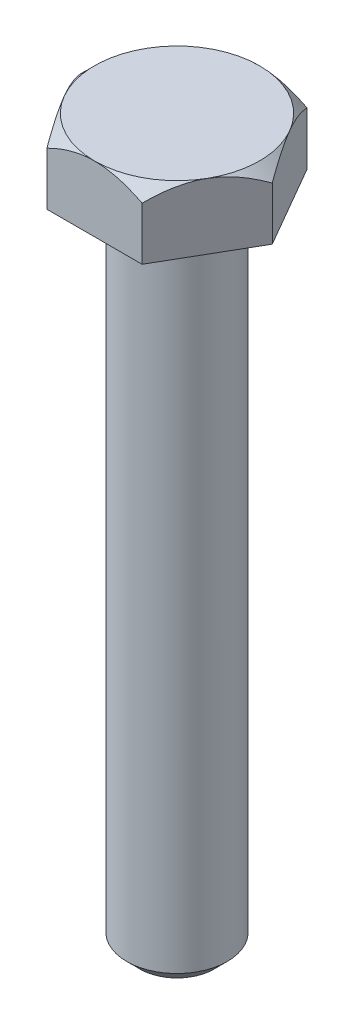
from build123d import *

# Parameters (mm, degrees)
EXTRUDE_1_DEPTH     = 5
SKETCH_8_OUTSIDE_W  = 22.464
SKETCH_8_OUTSIDE_H  = 20.522
SKETCH_8_OUTSIDE_R  = 6.278684177
CUT_EXTRUDE_1_DEPTH = 1
CUT_EXTRUDE_1_DRAFT = -45
SKETCH_9_R          = 3.825
BOLT_LENGTH_DEPTH   = 50
FILLET_1_R          = 1
CHAMFER_1_SIZE      = 1


with BuildPart() as part:
    # Эскиз6 → Бобышка-Вытянуть1 (new body)
    with BuildSketch(Plane(origin=(0, 0, 0), x_dir=(1, 0, 0), z_dir=(0, 1, 0))):
        Polygon((7.25, 0), (3.625, 6.278684177), (-3.625, 6.278684177), (-7.25, 0), (-3.625, -6.278684177), (3.625, -6.278684177), align=None)
    extrude(amount=EXTRUDE_1_DEPTH)


with BuildPart() as cut_extrude_1_tool:
    # Эскиз8 outside → Вырез-Вытянуть1 (with draft: the straight prism first)
    with BuildSketch(Plane(origin=(0, 5, 0), x_dir=(1, 0, 0), z_dir=(0, 1, 0))):
        Rectangle(SKETCH_8_OUTSIDE_W, SKETCH_8_OUTSIDE_H)
        Circle(SKETCH_8_OUTSIDE_R, mode=Mode.SUBTRACT)
    extrude(amount=-CUT_EXTRUDE_1_DEPTH)
    # Вырез-Вытянуть1: the draft: its side faces are tilted about the plane it starts from
    cut_extrude_1_sides = [cut_extrude_1_tool.faces().sort_by_distance(p)[0] for p in [
        (0, 4.5, 10.261),
        (11.232, 4.5, 0),
        (0, 4.5, -10.261),
        (-11.232, 4.5, 0),
        (-6.278684177, 4.5, 0),
    ]]
    draft(cut_extrude_1_sides, Plane(origin=(0, 5, 0), x_dir=(1, 0, 0), z_dir=(0, 1, 0)), CUT_EXTRUDE_1_DRAFT)


with BuildPart() as part_1:
    add(part.part)

    # Вырез-Вытянуть1: cut by cut_extrude_1_tool
    add(cut_extrude_1_tool.part, mode=Mode.SUBTRACT)

    # Эскиз9 → bolt length (add)
    with BuildSketch(Plane.XZ):
        with Locations(Location((0, 0, 0), (0, 0, 90))):  # turned: the seam where the file's is
            Circle(SKETCH_9_R)
    extrude(amount=BOLT_LENGTH_DEPTH)

    # Скругление1
    fillet_1_edges = [part_1.edges().sort_by_distance(p)[0] for p in [
        (0, 0, -3.825),
    ]]
    fillet(fillet_1_edges, radius=FILLET_1_R)

    # Фаска1
    chamfer_1_edges = [part_1.edges().sort_by_distance(p)[0] for p in [
        (0, -50, -3.825),
    ]]
    chamfer(chamfer_1_edges, length=CHAMFER_1_SIZE)


solid = part_1.part
